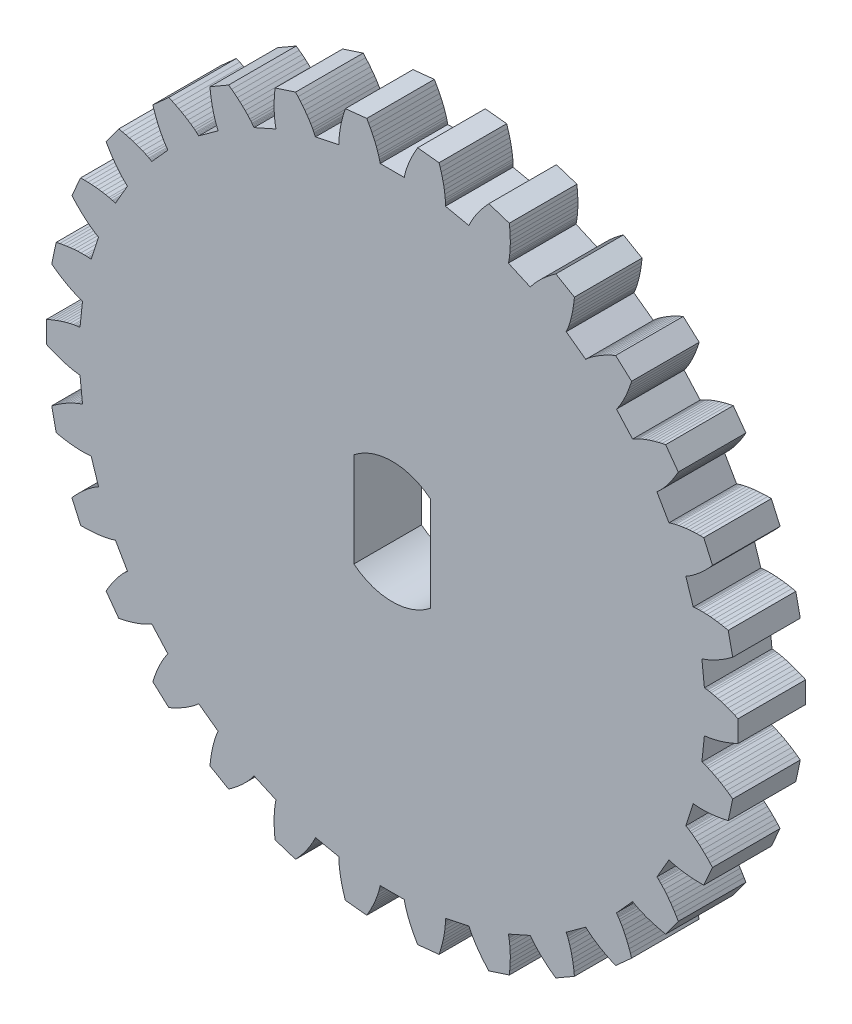
from build123d import *

# Parameters (mm, degrees)
BOSS_EXTRUDE1_DEPTH = 3


with BuildPart() as part:
    # Model → Boss-Extrude1 (new body)
    with BuildSketch(Plane.XY):
        Polygon((29.209, 16.2732), (29.246, 16.2699), (29.2831, 16.266), (29.3202, 16.2615), (29.3573, 16.2565), (29.4317, 16.245), (29.5061, 16.2317), (29.6552, 16.2001), (29.8045, 16.1625), (29.954, 16.1194), (30.1035, 16.0712), (30.2531, 16.0181), (30.4025, 15.9603), (30.5519, 15.8981), (30.7012, 15.8315), (30.7012, 14.8771), (30.5519, 14.8105), (30.4025, 14.7482), (30.2531, 14.6905), (30.1035, 14.6374), (29.954, 14.5891), (29.8045, 14.5461), (29.6552, 14.5085), (29.5061, 14.4769), (29.4317, 14.4636), (29.3573, 14.4521), (29.3202, 14.4471), (29.2831, 14.4426), (29.246, 14.4387), (29.209, 14.4354), (29.0973, 13.3725), (29.1328, 13.3616), (29.1683, 13.3501), (29.2036, 13.338), (29.2389, 13.3254), (29.3092, 13.2987), (29.3793, 13.2702), (29.5185, 13.2083), (29.6568, 13.1405), (29.794, 13.0673), (29.9303, 12.989), (30.0655, 12.906), (30.1997, 12.8184), (30.3329, 12.7264), (30.465, 12.6303), (30.2666, 11.6967), (30.1068, 11.6626), (29.9477, 11.6328), (29.7895, 11.6074), (29.6321, 11.5865), (29.4759, 11.5704), (29.3207, 11.5594), (29.1668, 11.5536), (29.0144, 11.5537), (28.9389, 11.5562), (28.8637, 11.5604), (28.8264, 11.5632), (28.7892, 11.5666), (28.7521, 11.5704), (28.7152, 11.5749), (28.3849, 10.5585), (28.4174, 10.5404), (28.4497, 10.5218), (28.4818, 10.5026), (28.5137, 10.4829), (28.5769, 10.4422), (28.6395, 10.3998), (28.7628, 10.3103), (28.884, 10.2152), (29.003, 10.115), (29.12, 10.0102), (29.235, 9.9008), (29.3481, 9.7873), (29.4592, 9.6696), (29.5684, 9.5481), (29.1802, 8.6762), (29.0168, 8.6761), (28.8551, 8.68), (28.695, 8.688), (28.5368, 8.7003), (28.3806, 8.7171), (28.2265, 8.7385), (28.0748, 8.7649), (27.9257, 8.7967), (27.8523, 8.8148), (27.7797, 8.8345), (27.7438, 8.8451), (27.7081, 8.8561), (27.6726, 8.8676), (27.6375, 8.8796), (27.1031, 7.9541), (27.1311, 7.9296), (27.1588, 7.9047), (27.1862, 7.8793), (27.2133, 7.8534), (27.2667, 7.8004), (27.3191, 7.7459), (27.4211, 7.6327), (27.5198, 7.5145), (27.6154, 7.3918), (27.708, 7.2649), (27.7978, 7.134), (27.8848, 6.9994), (27.9691, 6.8613), (28.0507, 6.7197), (27.4897, 5.9476), (27.3298, 5.9814), (27.1724, 6.0188), (27.0175, 6.06), (26.8653, 6.1049), (26.7159, 6.1538), (26.5697, 6.2068), (26.4268, 6.2641), (26.2876, 6.3262), (26.2196, 6.3592), (26.1527, 6.3936), (26.1197, 6.4114), (26.0871, 6.4296), (26.0548, 6.4482), (26.0229, 6.4673), (25.3078, 5.6731), (25.3301, 5.6433), (25.352, 5.6132), (25.3735, 5.5826), (25.3946, 5.5517), (25.4358, 5.4888), (25.4757, 5.4245), (25.552, 5.2926), (25.624, 5.1565), (25.692, 5.0166), (25.7562, 4.8732), (25.8168, 4.7265), (25.8739, 4.5768), (25.9276, 4.4241), (25.978, 4.2687), (25.2687, 3.63), (25.1194, 3.6964), (24.9732, 3.7657), (24.8302, 3.8382), (24.6907, 3.9138), (24.5548, 3.9926), (24.4227, 4.0749), (24.2949, 4.1607), (24.1717, 4.2503), (24.112, 4.2968), (24.0537, 4.3443), (24.0251, 4.3685), (23.997, 4.3931), (23.9693, 4.4181), (23.9421, 4.4434), (23.0774, 3.8152), (23.0931, 3.7815), (23.1082, 3.7474), (23.1229, 3.7131), (23.1371, 3.6784), (23.1644, 3.6083), (23.19, 3.5372), (23.2372, 3.3922), (23.2793, 3.2441), (23.3168, 3.0932), (23.3498, 2.9395), (23.3785, 2.7835), (23.4033, 2.6251), (23.4241, 2.4646), (23.441, 2.3021), (22.6144, 1.8249), (22.4822, 1.9208), (22.3536, 2.0191), (22.2288, 2.1197), (22.108, 2.2226), (21.9915, 2.328), (21.8795, 2.4359), (21.7722, 2.5464), (21.6703, 2.6598), (21.6216, 2.7176), (21.5745, 2.7762), (21.5516, 2.8058), (21.5292, 2.8357), (21.5072, 2.8659), (21.4859, 2.8963), (20.5095, 2.4616), (20.5178, 2.4254), (20.5256, 2.3889), (20.5328, 2.3523), (20.5395, 2.3154), (20.5516, 2.2411), (20.5619, 2.1662), (20.5779, 2.0147), (20.5883, 1.8611), (20.5935, 1.7056), (20.5939, 1.5485), (20.5896, 1.3898), (20.5808, 1.2298), (20.5678, 1.0685), (20.5506, 0.906), (19.6429, 0.6111), (19.5334, 0.7324), (19.4281, 0.8553), (19.3269, 0.9796), (19.2302, 1.1054), (19.1381, 1.2327), (19.051, 1.3615), (18.9691, 1.4919), (18.893, 1.624), (18.8573, 1.6907), (18.8234, 1.7578), (18.8072, 1.7916), (18.7915, 1.8255), (18.7763, 1.8595), (18.7617, 1.8937), (17.7163, 1.6715), (17.7169, 1.6343), (17.7169, 1.5971), (17.7164, 1.5597), (17.7153, 1.5223), (17.7116, 1.4471), (17.7061, 1.3717), (17.6903, 1.2201), (17.6685, 1.0677), (17.6413, 0.9146), (17.609, 0.7608), (17.5718, 0.6065), (17.53, 0.4518), (17.4837, 0.2967), (17.4331, 0.1414), (16.4839, 0.0416), (16.402, 0.183), (16.3245, 0.3251), (16.2515, 0.4677), (16.183, 0.6109), (16.1194, 0.7546), (16.0609, 0.8987), (16.008, 1.0433), (15.961, 1.1883), (15.9399, 1.2609), (15.9207, 1.3336), (15.9119, 1.3701), (15.9036, 1.4065), (15.8958, 1.4429), (15.8887, 1.4794), (14.8199, 1.4794), (14.8128, 1.4429), (14.805, 1.4065), (14.7967, 1.3701), (14.7878, 1.3336), (14.7686, 1.2609), (14.7476, 1.1883), (14.7006, 1.0433), (14.6476, 0.8987), (14.5891, 0.7546), (14.5256, 0.6109), (14.4571, 0.4677), (14.384, 0.3251), (14.3065, 0.183), (14.2247, 0.0416), (13.2755, 0.1414), (13.2249, 0.2967), (13.1786, 0.4518), (13.1368, 0.6065), (13.0996, 0.7608), (13.0673, 0.9146), (13.04, 1.0677), (13.0183, 1.2201), (13.0024, 1.3717), (12.997, 1.4471), (12.9933, 1.5223), (12.9922, 1.5597), (12.9916, 1.5971), (12.9916, 1.6343), (12.9922, 1.6715), (11.9468, 1.8937), (11.9323, 1.8595), (11.9171, 1.8255), (11.9014, 1.7916), (11.8852, 1.7578), (11.8513, 1.6907), (11.8156, 1.624), (11.7395, 1.4919), (11.6576, 1.3615), (11.5704, 1.2327), (11.4783, 1.1054), (11.3816, 0.9796), (11.2805, 0.8553), (11.1751, 0.7324), (11.0657, 0.6111), (10.158, 0.906), (10.1408, 1.0685), (10.1277, 1.2298), (10.119, 1.3898), (10.1147, 1.5485), (10.115, 1.7056), (10.1203, 1.8611), (10.1306, 2.0147), (10.1467, 2.1662), (10.157, 2.2411), (10.1691, 2.3154), (10.1758, 2.3523), (10.183, 2.3889), (10.1907, 2.4254), (10.199, 2.4616), (9.2227, 2.8963), (9.2013, 2.8659), (9.1794, 2.8357), (9.157, 2.8058), (9.1341, 2.7762), (9.087, 2.7176), (9.0382, 2.6598), (8.9363, 2.5464), (8.8291, 2.4359), (8.7171, 2.328), (8.6005, 2.2226), (8.4798, 2.1197), (8.355, 2.0191), (8.2264, 1.9208), (8.0941, 1.8249), (7.2676, 2.3021), (7.2845, 2.4646), (7.3053, 2.6251), (7.33, 2.7835), (7.3588, 2.9395), (7.3918, 3.0932), (7.4292, 3.2441), (7.4713, 3.3922), (7.5185, 3.5372), (7.5442, 3.6083), (7.5714, 3.6784), (7.5857, 3.7131), (7.6003, 3.7474), (7.6155, 3.7815), (7.6312, 3.8152), (6.7665, 4.4434), (6.7393, 4.4181), (6.7116, 4.3931), (6.6835, 4.3685), (6.6549, 4.3443), (6.5966, 4.2968), (6.5369, 4.2503), (6.4137, 4.1607), (6.2858, 4.0749), (6.1538, 3.9926), (6.0179, 3.9138), (5.8784, 3.8382), (5.7354, 3.7657), (5.5892, 3.6964), (5.4399, 3.63), (4.7306, 4.2687), (4.7809, 4.4241), (4.8346, 4.5768), (4.8918, 4.7265), (4.9524, 4.8732), (5.0166, 5.0166), (5.0846, 5.1565), (5.1565, 5.2926), (5.2328, 5.4245), (5.2728, 5.4888), (5.314, 5.5517), (5.3351, 5.5826), (5.3566, 5.6132), (5.3785, 5.6433), (5.4008, 5.6731), (4.6857, 6.4673), (4.6538, 6.4482), (4.6215, 6.4296), (4.5889, 6.4114), (4.5559, 6.3936), (4.489, 6.3592), (4.4209, 6.3262), (4.2818, 6.2641), (4.1389, 6.2068), (3.9926, 6.1538), (3.8433, 6.1049), (3.6911, 6.06), (3.5362, 6.0188), (3.3788, 5.9814), (3.2189, 5.9476), (2.6579, 6.7197), (2.7395, 6.8613), (2.8238, 6.9994), (2.9108, 7.134), (3.0005, 7.2649), (3.0932, 7.3918), (3.1887, 7.5145), (3.2875, 7.6327), (3.3895, 7.7459), (3.4419, 7.8004), (3.4953, 7.8534), (3.5224, 7.8793), (3.5498, 7.9047), (3.5775, 7.9296), (3.6055, 7.9541), (3.0711, 8.8796), (3.0359, 8.8676), (3.0005, 8.8561), (2.9648, 8.8451), (2.9288, 8.8345), (2.8562, 8.8148), (2.7828, 8.7967), (2.6338, 8.7649), (2.4821, 8.7385), (2.328, 8.7171), (2.1718, 8.7003), (2.0136, 8.688), (1.8535, 8.68), (1.6917, 8.6761), (1.5283, 8.6762), (1.1401, 9.5481), (1.2494, 9.6696), (1.3605, 9.7873), (1.4736, 9.9008), (1.5886, 10.0102), (1.7056, 10.115), (1.8246, 10.2152), (1.9457, 10.3103), (2.0691, 10.3998), (2.1317, 10.4422), (2.1949, 10.4829), (2.2268, 10.5026), (2.2589, 10.5218), (2.2911, 10.5404), (2.3236, 10.5585), (1.9934, 11.5749), (1.9565, 11.5704), (1.9194, 11.5666), (1.8822, 11.5632), (1.8448, 11.5604), (1.7697, 11.5562), (1.6941, 11.5537), (1.5417, 11.5536), (1.3879, 11.5594), (1.2327, 11.5704), (1.0764, 11.5865), (0.9191, 11.6074), (0.7609, 11.6328), (0.6018, 11.6626), (0.442, 11.6967), (0.2436, 12.6303), (0.3757, 12.7264), (0.5089, 12.8184), (0.6431, 12.906), (0.7783, 12.989), (0.9146, 13.0673), (1.0518, 13.1405), (1.19, 13.2083), (1.3293, 13.2702), (1.3993, 13.2987), (1.4697, 13.3254), (1.5049, 13.338), (1.5403, 13.3501), (1.5757, 13.3616), (1.6113, 13.3725), (1.4996, 14.4354), (1.4625, 14.4387), (1.4255, 14.4426), (1.3884, 14.4471), (1.3512, 14.4521), (1.2769, 14.4636), (1.2025, 14.4769), (1.0534, 14.5085), (0.9041, 14.5461), (0.7546, 14.5891), (0.6051, 14.6374), (0.4555, 14.6905), (0.306, 14.7482), (0.1566, 14.8105), (0.0074, 14.8771), (0.0074, 15.8315), (0.1566, 15.8981), (0.306, 15.9603), (0.4555, 16.0181), (0.6051, 16.0712), (0.7546, 16.1194), (0.9041, 16.1625), (1.0534, 16.2001), (1.2025, 16.2317), (1.2769, 16.245), (1.3512, 16.2565), (1.3884, 16.2615), (1.4255, 16.266), (1.4625, 16.2699), (1.4996, 16.2732), (1.6113, 17.3361), (1.5757, 17.347), (1.5403, 17.3585), (1.5049, 17.3706), (1.4697, 17.3832), (1.3993, 17.4099), (1.3293, 17.4384), (1.19, 17.5003), (1.0518, 17.5681), (0.9146, 17.6413), (0.7783, 17.7196), (0.6431, 17.8026), (0.5089, 17.8902), (0.3757, 17.9821), (0.2436, 18.0783), (0.442, 19.0119), (0.6018, 19.046), (0.7609, 19.0758), (0.9191, 19.1012), (1.0764, 19.1221), (1.2327, 19.1381), (1.3879, 19.1492), (1.5417, 19.1549), (1.6941, 19.1548), (1.7697, 19.1524), (1.8448, 19.1482), (1.8822, 19.1453), (1.9194, 19.142), (1.9565, 19.1381), (1.9934, 19.1336), (2.3236, 20.1501), (2.2911, 20.1681), (2.2589, 20.1868), (2.2268, 20.206), (2.1949, 20.2256), (2.1317, 20.2664), (2.0691, 20.3088), (1.9457, 20.3983), (1.8246, 20.4934), (1.7056, 20.5935), (1.5886, 20.6984), (1.4736, 20.8077), (1.3605, 20.9213), (1.2494, 21.0389), (1.1401, 21.1605), (1.5283, 22.0324), (1.6917, 22.0325), (1.8535, 22.0286), (2.0136, 22.0206), (2.1718, 22.0083), (2.328, 21.9915), (2.4821, 21.9701), (2.6338, 21.9437), (2.7828, 21.9119), (2.8562, 21.8938), (2.9288, 21.874), (2.9648, 21.8635), (3.0005, 21.8525), (3.0359, 21.841), (3.0711, 21.8289), (3.6055, 22.7545), (3.5775, 22.7789), (3.5498, 22.8039), (3.5224, 22.8293), (3.4953, 22.8552), (3.4419, 22.9082), (3.3895, 22.9627), (3.2875, 23.0759), (3.1887, 23.194), (3.0932, 23.3168), (3.0005, 23.4437), (2.9108, 23.5745), (2.8238, 23.7091), (2.7395, 23.8473), (2.6579, 23.9889), (3.2189, 24.761), (3.3788, 24.7272), (3.5362, 24.6897), (3.6911, 24.6486), (3.8433, 24.6037), (3.9926, 24.5548), (4.1389, 24.5018), (4.2818, 24.4444), (4.4209, 24.3823), (4.489, 24.3494), (4.5559, 24.315), (4.5889, 24.2972), (4.6215, 24.279), (4.6538, 24.2604), (4.6857, 24.2413), (5.4008, 25.0355), (5.3785, 25.0652), (5.3566, 25.0954), (5.3351, 25.1259), (5.314, 25.1569), (5.2728, 25.2198), (5.2328, 25.284), (5.1565, 25.416), (5.0846, 25.5521), (5.0166, 25.692), (4.9524, 25.8354), (4.8918, 25.9821), (4.8346, 26.1318), (4.7809, 26.2845), (4.7306, 26.4399), (5.4399, 27.0785), (5.5892, 27.0122), (5.7354, 26.9429), (5.8784, 26.8704), (6.0179, 26.7948), (6.1538, 26.7159), (6.2858, 26.6337), (6.4137, 26.5479), (6.5369, 26.4582), (6.5966, 26.4118), (6.6549, 26.3643), (6.6835, 26.34), (6.7116, 26.3154), (6.7393, 26.2905), (6.7665, 26.2652), (7.6312, 26.8934), (7.6155, 26.9271), (7.6003, 26.9612), (7.5857, 26.9955), (7.5714, 27.0302), (7.5442, 27.1003), (7.5185, 27.1714), (7.4713, 27.3163), (7.4292, 27.4644), (7.3918, 27.6154), (7.3588, 27.769), (7.33, 27.9251), (7.3053, 28.0834), (7.2845, 28.2439), (7.2676, 28.4065), (8.0941, 28.8837), (8.2264, 28.7877), (8.355, 28.6895), (8.4798, 28.5889), (8.6005, 28.4859), (8.7171, 28.3806), (8.8291, 28.2727), (8.9363, 28.1621), (9.0382, 28.0488), (9.087, 27.991), (9.1341, 27.9324), (9.157, 27.9027), (9.1794, 27.8728), (9.2013, 27.8427), (9.2227, 27.8123), (10.199, 28.247), (10.1907, 28.2832), (10.183, 28.3196), (10.1758, 28.3563), (10.1691, 28.3932), (10.157, 28.4674), (10.1467, 28.5423), (10.1306, 28.6939), (10.1203, 28.8475), (10.115, 29.003), (10.1147, 29.1601), (10.119, 29.3187), (10.1277, 29.4788), (10.1408, 29.6401), (10.158, 29.8026), (11.0657, 30.0975), (11.1751, 29.9762), (11.2805, 29.8533), (11.3816, 29.729), (11.4783, 29.6032), (11.5704, 29.4759), (11.6576, 29.347), (11.7395, 29.2166), (11.8156, 29.0846), (11.8513, 29.0179), (11.8852, 28.9508), (11.9014, 28.917), (11.9171, 28.8831), (11.9323, 28.8491), (11.9468, 28.8149), (12.9922, 29.0371), (12.9916, 29.0742), (12.9916, 29.1115), (12.9922, 29.1489), (12.9933, 29.1863), (12.997, 29.2614), (13.0024, 29.3369), (13.0183, 29.4884), (13.04, 29.6409), (13.0673, 29.794), (13.0996, 29.9478), (13.1368, 30.1021), (13.1786, 30.2568), (13.2249, 30.4118), (13.2755, 30.5672), (14.2247, 30.667), (14.3065, 30.5255), (14.384, 30.3835), (14.4571, 30.2408), (14.5256, 30.0976), (14.5891, 29.954), (14.6476, 29.8098), (14.7006, 29.6653), (14.7476, 29.5203), (14.7686, 29.4477), (14.7878, 29.3749), (14.7967, 29.3385), (14.805, 29.3021), (14.8128, 29.2656), (14.8199, 29.2292), (15.8887, 29.2292), (15.8958, 29.2656), (15.9036, 29.3021), (15.9119, 29.3385), (15.9207, 29.3749), (15.9399, 29.4477), (15.961, 29.5203), (16.008, 29.6653), (16.0609, 29.8098), (16.1194, 29.954), (16.183, 30.0976), (16.2515, 30.2408), (16.3245, 30.3835), (16.402, 30.5255), (16.4839, 30.667), (17.4331, 30.5672), (17.4837, 30.4118), (17.53, 30.2568), (17.5718, 30.1021), (17.609, 29.9478), (17.6413, 29.794), (17.6685, 29.6409), (17.6903, 29.4884), (17.7061, 29.3369), (17.7116, 29.2614), (17.7153, 29.1863), (17.7164, 29.1489), (17.7169, 29.1115), (17.7169, 29.0742), (17.7163, 29.0371), (18.7617, 28.8149), (18.7763, 28.8491), (18.7915, 28.8831), (18.8072, 28.917), (18.8234, 28.9508), (18.8573, 29.0179), (18.893, 29.0846), (18.9691, 29.2166), (19.051, 29.347), (19.1381, 29.4759), (19.2302, 29.6032), (19.3269, 29.729), (19.4281, 29.8533), (19.5334, 29.9762), (19.6429, 30.0975), (20.5506, 29.8026), (20.5678, 29.6401), (20.5808, 29.4788), (20.5896, 29.3187), (20.5939, 29.1601), (20.5935, 29.003), (20.5883, 28.8475), (20.5779, 28.6939), (20.5619, 28.5423), (20.5516, 28.4674), (20.5395, 28.3932), (20.5328, 28.3563), (20.5256, 28.3196), (20.5178, 28.2832), (20.5095, 28.247), (21.4859, 27.8123), (21.5072, 27.8427), (21.5292, 27.8728), (21.5516, 27.9027), (21.5745, 27.9324), (21.6216, 27.991), (21.6703, 28.0488), (21.7722, 28.1621), (21.8795, 28.2727), (21.9915, 28.3806), (22.108, 28.4859), (22.2288, 28.5889), (22.3536, 28.6895), (22.4822, 28.7877), (22.6144, 28.8837), (23.441, 28.4065), (23.4241, 28.2439), (23.4033, 28.0834), (23.3785, 27.9251), (23.3498, 27.769), (23.3168, 27.6154), (23.2793, 27.4644), (23.2372, 27.3163), (23.19, 27.1714), (23.1644, 27.1003), (23.1371, 27.0302), (23.1229, 26.9955), (23.1082, 26.9612), (23.0931, 26.9271), (23.0774, 26.8934), (23.9421, 26.2652), (23.9693, 26.2905), (23.997, 26.3154), (24.0251, 26.34), (24.0537, 26.3643), (24.112, 26.4118), (24.1717, 26.4582), (24.2949, 26.5479), (24.4227, 26.6337), (24.5548, 26.7159), (24.6907, 26.7948), (24.8302, 26.8704), (24.9732, 26.9429), (25.1194, 27.0122), (25.2687, 27.0785), (25.978, 26.4399), (25.9276, 26.2845), (25.8739, 26.1318), (25.8168, 25.9821), (25.7562, 25.8354), (25.692, 25.692), (25.624, 25.5521), (25.552, 25.416), (25.4757, 25.284), (25.4358, 25.2198), (25.3946, 25.1569), (25.3735, 25.1259), (25.352, 25.0954), (25.3301, 25.0652), (25.3078, 25.0355), (26.0229, 24.2413), (26.0548, 24.2604), (26.0871, 24.279), (26.1197, 24.2972), (26.1527, 24.315), (26.2196, 24.3494), (26.2876, 24.3823), (26.4268, 24.4444), (26.5697, 24.5018), (26.7159, 24.5548), (26.8653, 24.6037), (27.0175, 24.6486), (27.1724, 24.6897), (27.3298, 24.7272), (27.4897, 24.761), (28.0507, 23.9889), (27.9691, 23.8473), (27.8848, 23.7091), (27.7978, 23.5745), (27.708, 23.4437), (27.6154, 23.3168), (27.5198, 23.194), (27.4211, 23.0759), (27.3191, 22.9627), (27.2667, 22.9082), (27.2133, 22.8552), (27.1862, 22.8293), (27.1588, 22.8039), (27.1311, 22.7789), (27.1031, 22.7545), (27.6375, 21.8289), (27.6726, 21.841), (27.7081, 21.8525), (27.7438, 21.8635), (27.7797, 21.874), (27.8523, 21.8938), (27.9257, 21.9119), (28.0748, 21.9437), (28.2265, 21.9701), (28.3806, 21.9915), (28.5368, 22.0083), (28.695, 22.0206), (28.8551, 22.0286), (29.0168, 22.0325), (29.1802, 22.0324), (29.5684, 21.1605), (29.4592, 21.0389), (29.3481, 20.9213), (29.235, 20.8077), (29.12, 20.6984), (29.003, 20.5935), (28.884, 20.4934), (28.7628, 20.3983), (28.6395, 20.3088), (28.5769, 20.2664), (28.5137, 20.2256), (28.4818, 20.206), (28.4497, 20.1868), (28.4174, 20.1681), (28.3849, 20.1501), (28.7152, 19.1336), (28.7521, 19.1381), (28.7892, 19.142), (28.8264, 19.1453), (28.8637, 19.1482), (28.9389, 19.1524), (29.0144, 19.1548), (29.1668, 19.1549), (29.3207, 19.1492), (29.4759, 19.1381), (29.6321, 19.1221), (29.7895, 19.1012), (29.9477, 19.0758), (30.1068, 19.046), (30.2666, 19.0119), (30.465, 18.0783), (30.3329, 17.9821), (30.1997, 17.8902), (30.0655, 17.8026), (29.9303, 17.7196), (29.794, 17.6413), (29.6568, 17.5681), (29.5185, 17.5003), (29.3793, 17.4384), (29.3092, 17.4099), (29.2389, 17.3832), (29.2036, 17.3706), (29.1683, 17.3585), (29.1328, 17.347), (29.0973, 17.3361), align=None)
        with BuildLine():
            Line((13.6543, 17.451917696), (13.6543, 13.256682304))
            ThreePointArc((13.6543, 13.256682304), (15.3543, 12.6543), (17.0543, 13.256682304))
            Line((17.0543, 13.256682304), (17.0543, 17.451917696))
            ThreePointArc((17.0543, 17.451917696), (15.3543, 18.0543), (13.6543, 17.451917696))
        make_face(mode=Mode.SUBTRACT)
    extrude(amount=BOSS_EXTRUDE1_DEPTH)


solid = part.part
